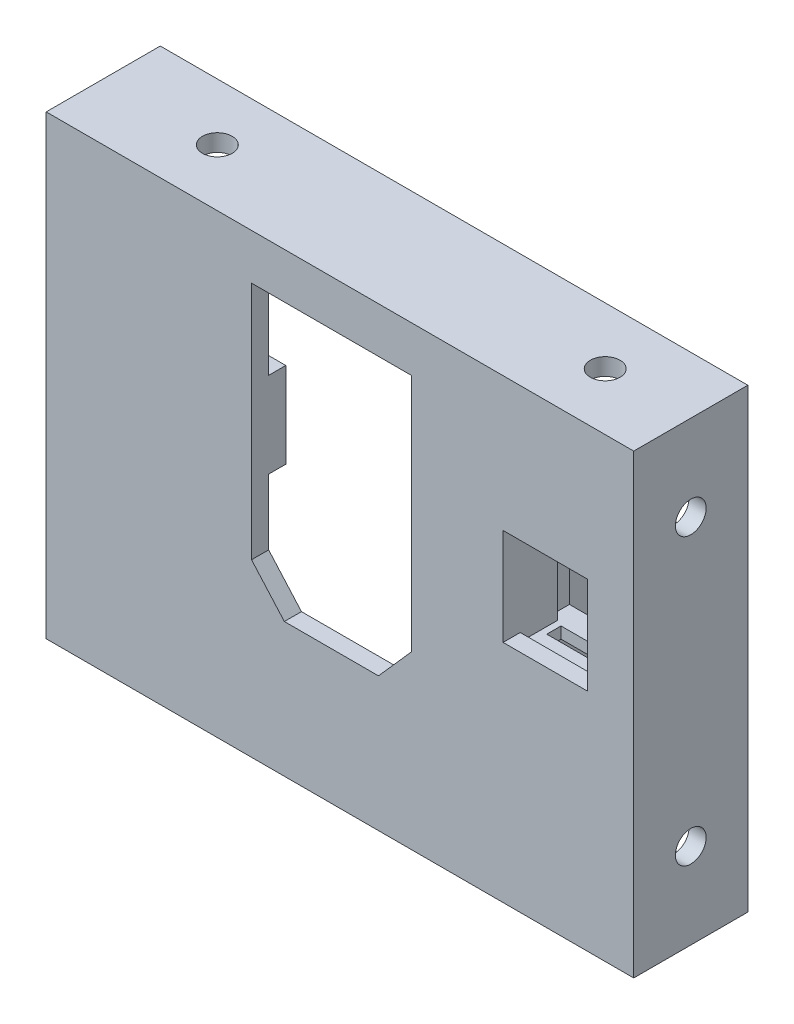
from build123d import *

# Parameters (mm, degrees)
SKETCH1_W           = 75
SKETCH1_H           = 80
BOSS_EXTRUDE1_DEPTH = 3
SKETCH2_W           = 17
SKETCH2_H           = 80
BOSS_EXTRUDE2_DEPTH = 3
SKETCH7_W           = 25
SKETCH7_H           = 80
SKETCH7_W_2         = 14.8
SKETCH7_H_2         = 17
BOSS_EXTRUDE6_DEPTH = 3
SKETCH8_W           = 21.55
SKETCH8_H           = 23.85
SKETCH8_W_2         = 17.55
SKETCH8_H_2         = 19.85
BOSS_EXTRUDE7_DEPTH = 10
SKETCH9_W           = 12.5
SKETCH9_H           = 2.5
CUT_EXTRUDE3_DEPTH  = 23.85
SKETCH10_W          = 1.375
SKETCH10_H          = 19.85
BOSS_EXTRUDE8_DEPTH = 6.5
SKETCH11_W          = 20
SKETCH11_H          = 80
SKETCH11_R          = 2.7
BOSS_EXTRUDE9_DEPTH = 3
SKETCH3_W           = 8
SKETCH3_H           = 15
BOSS_EXTRUDE3_DEPTH = 3
SKETCH5_W           = 69
SKETCH5_H           = 17
SKETCH5_R           = 2.6
SKETCH5_W_2         = 25
BOSS_EXTRUDE4_DEPTH = 3
SKETCH21_R          = 2.7
CUT_EXTRUDE5_DEPTH  = 3


with BuildPart() as part:
    # Sketch1 → Boss-Extrude1 (new body)
    with BuildSketch(Plane.XY):
        with Locations((0, 40)):
            Rectangle(SKETCH1_W, SKETCH1_H)
        Polygon((4.25, 23.5), (20.75, 23.5), (26.5, 30), (26.5, 72), (-1.5, 72), (-1.5, 30), align=None, mode=Mode.SUBTRACT)
    extrude(amount=BOSS_EXTRUDE1_DEPTH)

    # Sketch2 → Boss-Extrude2 (add)
    with BuildSketch(Plane(origin=(37.5, 0, 0), x_dir=(0, 0, -1), z_dir=(1, 0, 0))):
        with Locations((8.5, 40)):
            Rectangle(SKETCH2_W, SKETCH2_H)
    boss_extrude2 = extrude(amount=-BOSS_EXTRUDE2_DEPTH)

    # Mirror1: Boss-Extrude2 across plane
    add(boss_extrude2.mirror(Plane(origin=(0, 0, 0), x_dir=(0, 0, 1), z_dir=(1, 0, 0))))

    # Sketch7 → Boss-Extrude6 (add)
    with BuildSketch(Plane.XY.offset(3)):
        with Locations((50, 40)):
            Rectangle(SKETCH7_W, SKETCH7_H)
        with Locations((50, 48.001193432)):
            Rectangle(SKETCH7_W_2, SKETCH7_H_2, mode=Mode.SUBTRACT)
    extrude(amount=-BOSS_EXTRUDE6_DEPTH)

    # Sketch8 → Boss-Extrude7 (add)
    with BuildSketch(Plane(origin=(0, 0, 0), x_dir=(-1, 0, 0), z_dir=(0, 0, -1))):
        with Locations((-50, 48.001193432)):
            Rectangle(SKETCH8_W, SKETCH8_H)
        with Locations((-50, 48.001193432)):
            Rectangle(SKETCH8_W_2, SKETCH8_H_2, mode=Mode.SUBTRACT)
    extrude(amount=BOSS_EXTRUDE7_DEPTH)

    # Sketch9 → Cut-Extrude3 (cut)
    with BuildSketch(Plane(origin=(0, 59.926193432, 0), x_dir=(1, 0, 0), z_dir=(0, 1, 0))):
        with Locations((50, 4.75)):
            Rectangle(SKETCH9_W, SKETCH9_H)
    extrude(amount=-CUT_EXTRUDE3_DEPTH, mode=Mode.SUBTRACT)

    # Sketch10 → Boss-Extrude8 (add)
    with BuildSketch(Plane(origin=(0, 0, 0), x_dir=(-1, 0, 0), z_dir=(0, 0, -1))):
        with Locations((-41.9125, 48.001193432)):
            Rectangle(SKETCH10_W, SKETCH10_H)
        with Locations((-58.0875, 48.001193432)):
            Rectangle(SKETCH10_W, SKETCH10_H)
    extrude(amount=BOSS_EXTRUDE8_DEPTH)

    # Sketch11 → Boss-Extrude9 (add)
    with BuildSketch(Plane(origin=(62.5, 0, 0), x_dir=(0, 0, -1), z_dir=(1, 0, 0))):
        with Locations((7, 40)):
            Rectangle(SKETCH11_W, SKETCH11_H)
        with Locations((7, 15)):
            Circle(SKETCH11_R, mode=Mode.SUBTRACT)
        with Locations((7, 65)):
            Circle(SKETCH11_R, mode=Mode.SUBTRACT)
    extrude(amount=BOSS_EXTRUDE9_DEPTH)

    # Sketch3 → Boss-Extrude3 (add)
    with BuildSketch(Plane(origin=(0, 0, 0), x_dir=(-1, 0, 0), z_dir=(0, 0, -1))):
        with Locations((-30.5, 49)):
            Rectangle(SKETCH3_W, SKETCH3_H)
        with Locations((5.5, 49)):
            Rectangle(SKETCH3_W, SKETCH3_H)
    extrude(amount=BOSS_EXTRUDE3_DEPTH)

    # Sketch5 → Boss-Extrude4 (add)
    with BuildSketch(Plane.XZ):
        with Locations((0, -8.5)):
            Rectangle(SKETCH5_W, SKETCH5_H)
        with Locations((-17.5, -7)):
            Circle(SKETCH5_R, mode=Mode.SUBTRACT)
        with Locations((50, -8.5)):
            Rectangle(SKETCH5_W_2, SKETCH5_H)
        with Locations((50.5, -7)):
            Circle(SKETCH5_R, mode=Mode.SUBTRACT)
    boss_extrude4 = extrude(amount=-BOSS_EXTRUDE4_DEPTH)

    # Mirror2: Boss-Extrude4 across plane
    add(boss_extrude4.mirror(Plane(origin=(0, 40, 0), x_dir=(0, 0, 1), z_dir=(0, -1, 0))))

    # Sketch21 → Cut-Extrude5 (cut)
    with BuildSketch(Plane(origin=(-34.5, 0, 0), x_dir=(0, 0, -1), z_dir=(1, 0, 0))):
        with Locations((7, 15)):
            Circle(SKETCH21_R)
        with Locations((7, 65)):
            Circle(SKETCH21_R)
    extrude(amount=-CUT_EXTRUDE5_DEPTH, mode=Mode.SUBTRACT)


solid = part.part
